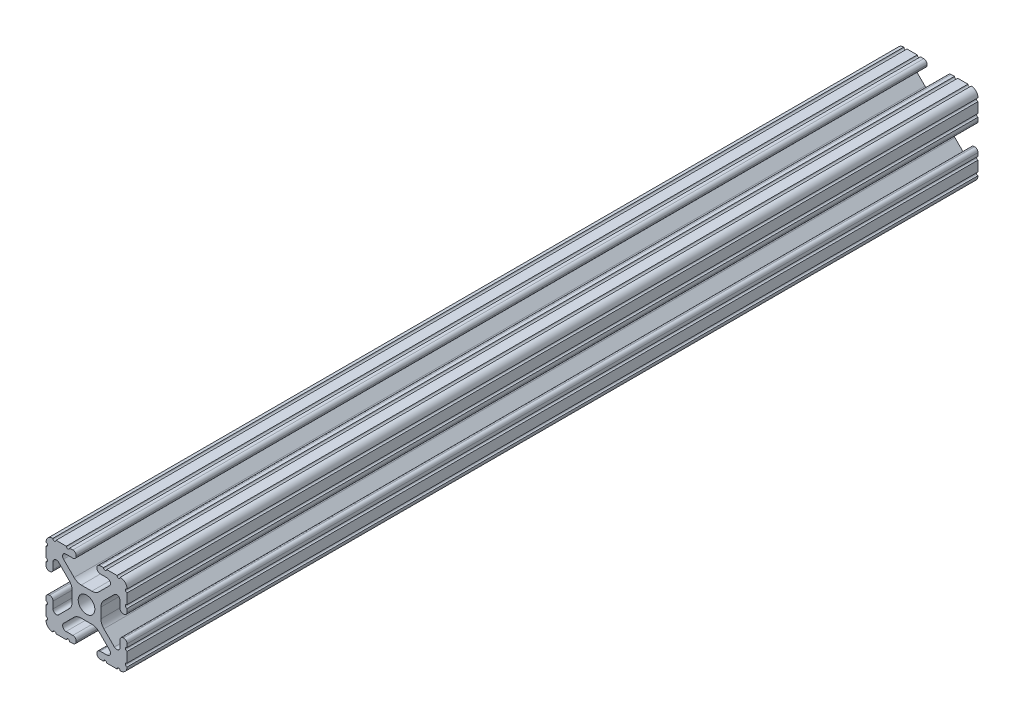
from build123d import *

# Parameters (mm, degrees)
SKETCH1_R      = 2.6035
EXTRUDE1_DEPTH = 266.7


with BuildPart() as part:
    # Sketch1 → Extrude1 (new body)
    with BuildSketch(Plane.XY):
        with BuildLine():
            Line((-7.207036008, 8.724370562), (-3.898272566, 5.423169045))
            ThreePointArc((-3.898272566, 5.423169045), (-2.869120213, 4.736787962), (-1.655778399, 4.4958))
            Line((-1.655778399, 4.4958), (1.655778399, 4.4958))
            ThreePointArc((1.655778399, 4.4958), (2.869120213, 4.736787962), (3.898272566, 5.423169045))
            Line((3.898272566, 5.423169045), (7.207036008, 8.724370562))
            ThreePointArc((7.207036008, 8.724370562), (7.432222385, 9.85140422), (6.476788598, 10.4902))
            Line((6.476788598, 10.4902), (4.287512407, 10.4902))
            ThreePointArc((4.287512407, 10.4902), (3.54574862, 10.79744862), (3.2385, 11.539212407))
            Line((3.2385, 11.539212407), (3.2385, 11.650987593))
            ThreePointArc((3.2385, 11.650987593), (3.54574862, 12.39275138), (4.287512407, 12.7))
            Line((4.287512407, 12.7), (5.317126718, 12.7))
            ThreePointArc((5.317126718, 12.7), (5.825126718, 12.192), (6.333126718, 12.7))
            Line((6.333126718, 12.7), (9.550443118, 12.7))
            ThreePointArc((9.550443118, 12.7), (10.058366869, 12.192000006), (10.566443095, 12.699847501))
            ThreePointArc((10.566443095, 12.699847501), (12.082537762, 12.08250727), (12.699846982, 10.566399977))
            ThreePointArc((12.699846982, 10.566399977), (12.192000006, 10.058323491), (12.7, 9.5504))
            Line((12.7, 9.5504), (12.7, 6.3330836))
            ThreePointArc((12.7, 6.3330836), (12.192, 5.8250836), (12.7, 5.3170836))
            Line((12.7, 5.3170836), (12.7, 4.287469289))
            ThreePointArc((12.7, 4.287469289), (12.39275138, 3.545705502), (11.650987593, 3.238456882))
            Line((11.650987593, 3.238456882), (11.539212407, 3.238456882))
            ThreePointArc((11.539212407, 3.238456882), (10.79744862, 3.545705502), (10.4902, 4.287469289))
            Line((10.4902, 4.287469289), (10.4902, 6.402089023))
            ThreePointArc((10.4902, 6.402089023), (9.856505071, 7.351067942), (8.737131347, 7.129408934))
            Line((8.737131347, 7.129408934), (5.441005833, 3.840816462))
            ThreePointArc((5.441005833, 3.840816462), (4.750877967, 2.809883091), (4.5085, 1.593185507))
            Line((4.5085, 1.593185507), (4.5085, -1.593185507))
            ThreePointArc((4.5085, -1.593185507), (4.750877967, -2.809883091), (5.441005833, -3.840816462))
            Line((5.441005833, -3.840816462), (8.737131347, -7.129408934))
            ThreePointArc((8.737131347, -7.129408934), (9.856505071, -7.351067942), (10.4902, -6.402089023))
            Line((10.4902, -6.402089023), (10.4902, -4.287469289))
            ThreePointArc((10.4902, -4.287469289), (10.79744862, -3.545705502), (11.539212407, -3.238456882))
            Line((11.539212407, -3.238456882), (11.650987593, -3.238456882))
            ThreePointArc((11.650987593, -3.238456882), (12.39275138, -3.545705502), (12.7, -4.287469289))
            Line((12.7, -4.287469289), (12.7, -5.3170836))
            ThreePointArc((12.7, -5.3170836), (12.192, -5.8250836), (12.7, -6.3330836))
            Line((12.7, -6.3330836), (12.7, -9.5504))
            ThreePointArc((12.7, -9.5504), (12.192000006, -10.058323491), (12.699846982, -10.566399977))
            ThreePointArc((12.699846982, -10.566399977), (12.082537762, -12.08250727), (10.566443095, -12.699847501))
            ThreePointArc((10.566443095, -12.699847501), (10.058366869, -12.192000006), (9.550443118, -12.7))
            Line((9.550443118, -12.7), (6.333126718, -12.7))
            ThreePointArc((6.333126718, -12.7), (5.825126718, -12.192), (5.317126718, -12.7))
            Line((5.317126718, -12.7), (4.287512407, -12.7))
            ThreePointArc((4.287512407, -12.7), (3.54574862, -12.39275138), (3.2385, -11.650987593))
            Line((3.2385, -11.650987593), (3.2385, -11.539212407))
            ThreePointArc((3.2385, -11.539212407), (3.54574862, -10.79744862), (4.287512407, -10.4902))
            Line((4.287512407, -10.4902), (6.416408329, -10.4902))
            ThreePointArc((6.416408329, -10.4902), (7.41473083, -9.822813117), (7.179650497, -8.645192506))
            Line((7.179650497, -8.645192506), (3.952270251, -5.423690499))
            ThreePointArc((3.952270251, -5.423690499), (2.922936451, -4.736929036), (1.709253557, -4.4958))
            Line((1.709253557, -4.4958), (-1.709253557, -4.4958))
            ThreePointArc((-1.709253557, -4.4958), (-2.922936451, -4.736929036), (-3.952270251, -5.423690499))
            Line((-3.952270251, -5.423690499), (-7.179650497, -8.645192506))
            ThreePointArc((-7.179650497, -8.645192506), (-7.41473083, -9.822813117), (-6.416408329, -10.4902))
            Line((-6.416408329, -10.4902), (-4.287512407, -10.4902))
            ThreePointArc((-4.287512407, -10.4902), (-3.54574862, -10.79744862), (-3.2385, -11.539212407))
            Line((-3.2385, -11.539212407), (-3.2385, -11.650987593))
            ThreePointArc((-3.2385, -11.650987593), (-3.54574862, -12.39275138), (-4.287512407, -12.7))
            Line((-4.287512407, -12.7), (-5.317126718, -12.7))
            ThreePointArc((-5.317126718, -12.7), (-5.825126718, -12.192), (-6.333126718, -12.7))
            Line((-6.333126718, -12.7), (-9.550443118, -12.7))
            ThreePointArc((-9.550443118, -12.7), (-10.058366869, -12.192000006), (-10.566443095, -12.699847501))
            ThreePointArc((-10.566443095, -12.699847501), (-12.082537762, -12.08250727), (-12.699846982, -10.566399977))
            ThreePointArc((-12.699846982, -10.566399977), (-12.192000006, -10.058323491), (-12.7, -9.5504))
            Line((-12.7, -9.5504), (-12.7, -6.3330836))
            ThreePointArc((-12.7, -6.3330836), (-12.192, -5.8250836), (-12.7, -5.3170836))
            Line((-12.7, -5.3170836), (-12.7, -4.287469289))
            ThreePointArc((-12.7, -4.287469289), (-12.39275138, -3.545705502), (-11.650987593, -3.238456882))
            Line((-11.650987593, -3.238456882), (-11.539212407, -3.238456882))
            ThreePointArc((-11.539212407, -3.238456882), (-10.79744862, -3.545705502), (-10.4902, -4.287469289))
            Line((-10.4902, -4.287469289), (-10.4902, -6.402089023))
            ThreePointArc((-10.4902, -6.402089023), (-9.856505071, -7.351067942), (-8.737131347, -7.129408934))
            Line((-8.737131347, -7.129408934), (-5.441005833, -3.840816462))
            ThreePointArc((-5.441005833, -3.840816462), (-4.750877967, -2.809883091), (-4.5085, -1.593185507))
            Line((-4.5085, -1.593185507), (-4.5085, 1.593185507))
            ThreePointArc((-4.5085, 1.593185507), (-4.750877967, 2.809883091), (-5.441005833, 3.840816462))
            Line((-5.441005833, 3.840816462), (-8.737131347, 7.129408934))
            ThreePointArc((-8.737131347, 7.129408934), (-9.856505071, 7.351067942), (-10.4902, 6.402089023))
            Line((-10.4902, 6.402089023), (-10.4902, 4.287469289))
            ThreePointArc((-10.4902, 4.287469289), (-10.79744862, 3.545705502), (-11.539212407, 3.238456882))
            Line((-11.539212407, 3.238456882), (-11.650987593, 3.238456882))
            ThreePointArc((-11.650987593, 3.238456882), (-12.39275138, 3.545705502), (-12.7, 4.287469289))
            Line((-12.7, 4.287469289), (-12.7, 5.3170836))
            ThreePointArc((-12.7, 5.3170836), (-12.192, 5.8250836), (-12.7, 6.3330836))
            Line((-12.7, 6.3330836), (-12.7, 9.5504))
            ThreePointArc((-12.7, 9.5504), (-12.192000006, 10.058323491), (-12.699846982, 10.566399977))
            ThreePointArc((-12.699846982, 10.566399977), (-12.082537762, 12.08250727), (-10.566443095, 12.699847501))
            ThreePointArc((-10.566443095, 12.699847501), (-10.058366869, 12.192000006), (-9.550443118, 12.7))
            Line((-9.550443118, 12.7), (-6.333126718, 12.7))
            ThreePointArc((-6.333126718, 12.7), (-5.825126718, 12.192), (-5.317126718, 12.7))
            Line((-5.317126718, 12.7), (-4.287512407, 12.7))
            ThreePointArc((-4.287512407, 12.7), (-3.54574862, 12.39275138), (-3.2385, 11.650987593))
            Line((-3.2385, 11.650987593), (-3.2385, 11.539212407))
            ThreePointArc((-3.2385, 11.539212407), (-3.54574862, 10.79744862), (-4.287512407, 10.4902))
            Line((-4.287512407, 10.4902), (-6.476788598, 10.4902))
            ThreePointArc((-6.476788598, 10.4902), (-7.432222385, 9.85140422), (-7.207036008, 8.724370562))
        make_face()
        Circle(SKETCH1_R, mode=Mode.SUBTRACT)
    extrude(amount=-EXTRUDE1_DEPTH)


solid = part.part
